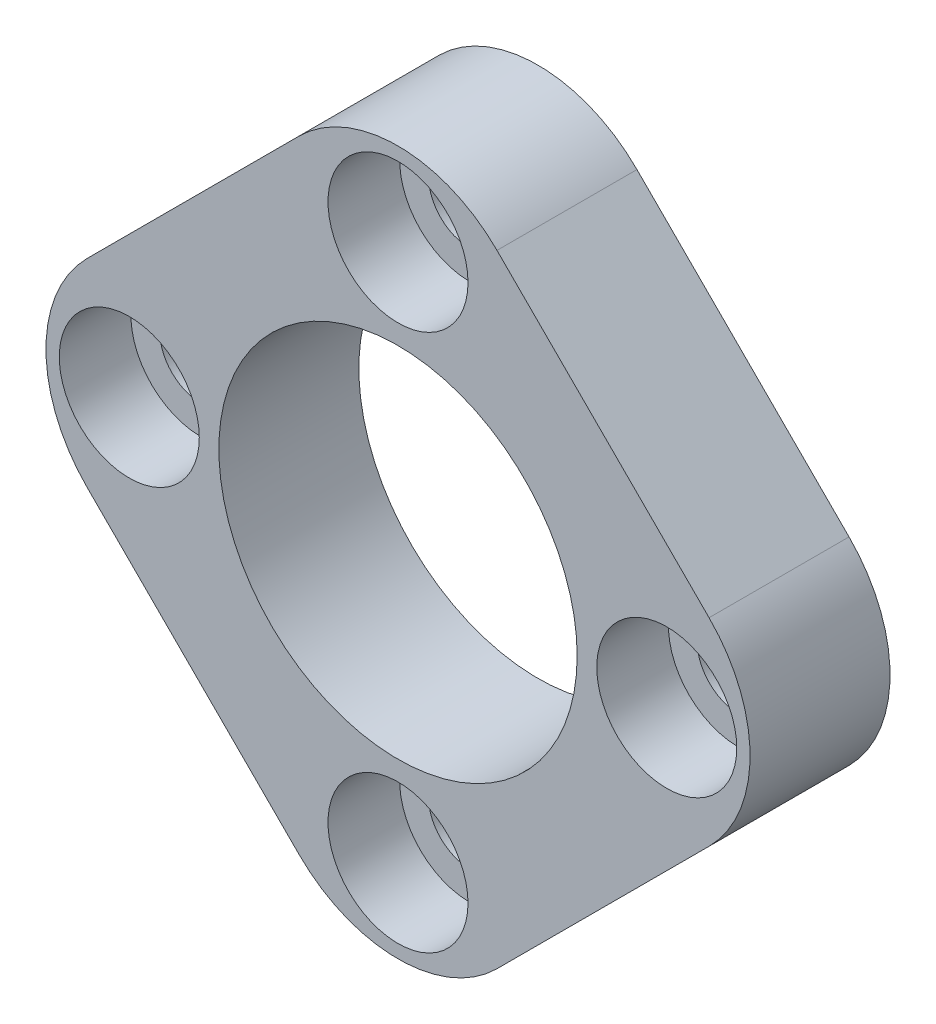
from build123d import *

# Parameters (mm, degrees)
BOSS_EXTRUDE1_DEPTH                            = 5.55625
SKETCH2_R                                      = 7.112
CUT_EXTRUDE1_DEPTH                             = 6.55625
CBORE_FOR_4_SOCKET_HEAD_CAP_SCREW1_D           = 3.2639
CBORE_FOR_4_SOCKET_HEAD_CAP_SCREW1_CBORE_D     = 5.55752
CBORE_FOR_4_SOCKET_HEAD_CAP_SCREW1_CBORE_DEPTH = 2.8448
CIRPATTERN1_COUNT                              = 4
FILLET1_R                                      = 5.55625


with BuildPart() as part:
    # Sketch1 → Boss-Extrude1 (new body)
    with BuildSketch(Plane.XY):
        Polygon((0, -16.276714219), (-16.276714219, 0), (0, 16.276714219), (16.276714219, 0), align=None)
    extrude(amount=-BOSS_EXTRUDE1_DEPTH)

    # Sketch2 → Cut-Extrude1 (cut, through all)
    with BuildSketch(Plane.XY):
        Circle(SKETCH2_R)
    extrude(amount=-CUT_EXTRUDE1_DEPTH, mode=Mode.SUBTRACT)

    # CBORE for #4 Socket Head Cap Screw1 (through all)
    with Locations(Plane.XY):
        with Locations((0, 10.668)):
            cbore_for_4_socket_head_cap_screw1 = CounterBoreHole(CBORE_FOR_4_SOCKET_HEAD_CAP_SCREW1_D / 2, CBORE_FOR_4_SOCKET_HEAD_CAP_SCREW1_CBORE_D / 2, CBORE_FOR_4_SOCKET_HEAD_CAP_SCREW1_CBORE_DEPTH)

    # CirPattern1: CBORE for #4 Socket Head Cap Screw1 ×4 about axis
    cirpattern1_axis = Axis((0, 0, 0), (0, 0, 1))
    for i in range(1, CIRPATTERN1_COUNT):
        add(cbore_for_4_socket_head_cap_screw1.rotate(cirpattern1_axis, i * 360 / CIRPATTERN1_COUNT), mode=Mode.SUBTRACT)

    # Fillet1
    fillet1_edges = [part.edges().sort_by_distance(p)[0] for p in [
        (0, -16.276714219, -2.778125),
        (-16.276714219, 0, -2.778125),
        (0, 16.276714219, -2.778125),
        (16.276714219, 0, -2.778125),
    ]]
    fillet(fillet1_edges, radius=FILLET1_R)


solid = part.part
